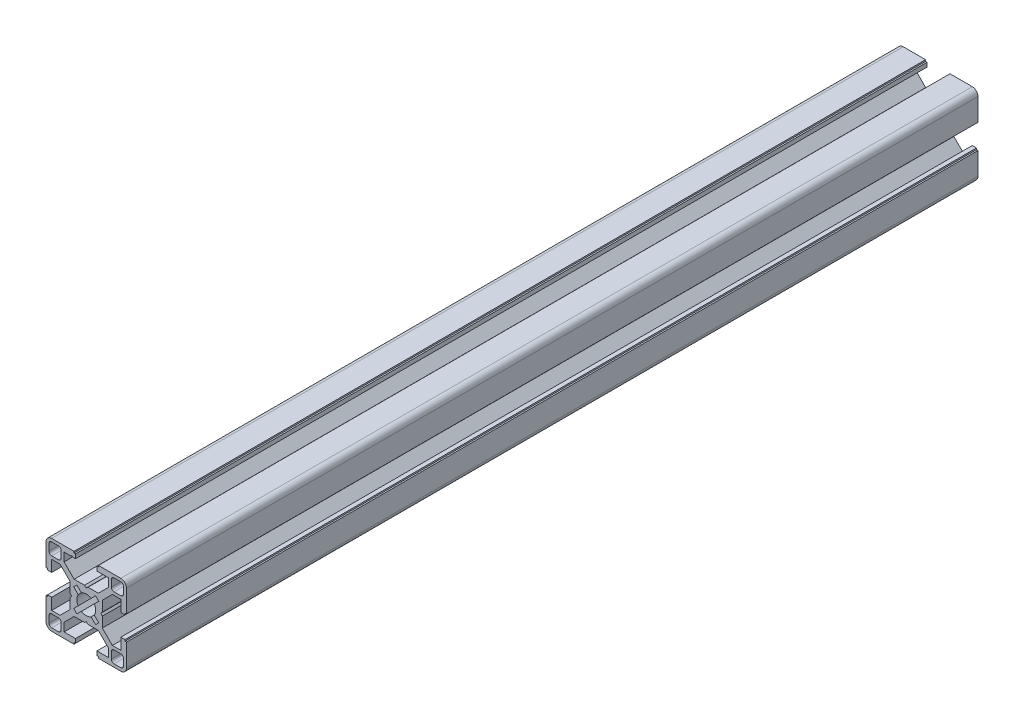
from build123d import *

# Parameters (mm, degrees)
BOSS_EXTRUDE1_DEPTH     = 317.5
CUT_EXTRUDE1_DEPTH      = 1
CUT_EXTRUDE1_DEPTH_BACK = 318.5


with BuildPart() as part:
    # Sketch4 → Boss-Extrude1 (new body)
    with BuildSketch(Plane.XY):
        with BuildLine():
            Line((0, -5.45), (0.655464476, -6))
            Line((0.655464476, -6), (4.504469158, -6))
            Line((4.504469158, -6), (8.25, -9.745530842))
            Line((8.25, -9.745530842), (8.25, -12.885))
            Line((8.25, -12.885), (4, -12.885))
            Line((4, -12.885), (4, -14.45))
            Line((4, -14.45), (4.55, -14.45))
            Line((4.55, -14.45), (4.55, -15))
            Line((4.55, -15), (12.885, -15))
            ThreePointArc((12.885, -15), (14.380530842, -14.380530842), (15, -12.885))
            Line((15, -12.885), (15, -4.55))
            Line((15, -4.55), (14.45, -4.55))
            Line((14.45, -4.55), (14.45, -4))
            Line((14.45, -4), (12.885, -4))
            Line((12.885, -4), (12.885, -8.25))
            Line((12.885, -8.25), (9.745530842, -8.25))
            Line((9.745530842, -8.25), (6, -4.504469158))
            Line((6, -4.504469158), (6, -0.655464476))
            Line((6, -0.655464476), (5.45, 0))
            Line((5.45, 0), (3.5, 0))
            ThreePointArc((3.5, 0), (3.371433308, -0.939913534), (2.995178599, -1.81077474))
            Line((2.995178599, -1.81077474), (4.675743591, -3.491339732))
            Line((4.675743591, -3.491339732), (3.491339732, -4.675743591))
            Line((3.491339732, -4.675743591), (1.81077474, -2.995178599))
            ThreePointArc((1.81077474, -2.995178599), (0.939913534, -3.371433308), (0, -3.5))
            Line((0, -3.5), (0, -5.45))
        make_face()
        with BuildLine():
            Line((9.375, -10.365), (9.375, -12.885))
            ThreePointArc((9.375, -12.885), (9.664964287, -13.585035713), (10.365, -13.875))
            Line((10.365, -13.875), (12.885, -13.875))
            ThreePointArc((12.885, -13.875), (13.585035713, -13.585035713), (13.875, -12.885))
            Line((13.875, -12.885), (13.875, -10.365))
            ThreePointArc((13.875, -10.365), (13.585035713, -9.664964287), (12.885, -9.375))
            Line((12.885, -9.375), (10.365, -9.375))
            ThreePointArc((10.365, -9.375), (9.664964287, -9.664964287), (9.375, -10.365))
        make_face(mode=Mode.SUBTRACT)
    extrude(amount=BOSS_EXTRUDE1_DEPTH)

    # Mirror1: part across plane


with BuildPart() as part_1:
    add(part.part)
    add(part.part.mirror(Plane(origin=(0, 0, 0), x_dir=(0, 0, 1), z_dir=(1, 0, 0))))

    # Mirror2: part across plane


with BuildPart() as part_2:
    add(part_1.part)
    add(part_1.part.mirror(Plane.ZX))

    # Sketch5 → Cut-Extrude1 (cut, two sides)
    with BuildSketch(Plane.XY.offset(317.5)) as cut_extrude1_sk:
        Polygon((-5.675, 12.885), (-5.4, 13.16), (-5.125, 12.885), align=None)
    extrude(amount=CUT_EXTRUDE1_DEPTH, mode=Mode.SUBTRACT)
    extrude(cut_extrude1_sk.sketch, amount=-CUT_EXTRUDE1_DEPTH_BACK, mode=Mode.SUBTRACT)


solid = part_2.part
